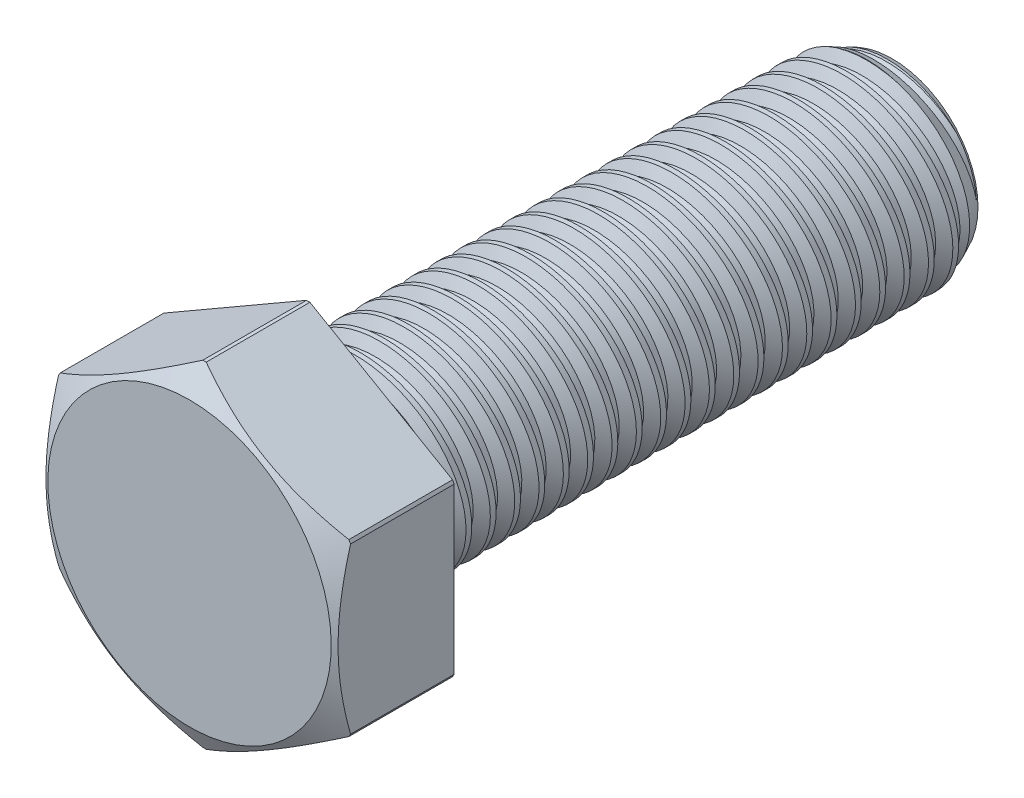
from build123d import *

# Parameters (mm, degrees)
SKETCH1_W            = 76.2
SKETCH1_H            = 12.7
LPATTERN1_COUNT      = 2
LPATTERN1_PITCH      = 3.175
LPATTERN1_COUNT_DIR2 = 24
LPATTERN1_PITCH_DIR2 = 3.175
EXTRUDE1_DEPTH       = 15.478125


with BuildPart() as part:
    # Sketch1 → Revolve1 (revolve)
    with BuildSketch(Plane(origin=(0, 0, 0), x_dir=(0, 0, -1), z_dir=(1, 0, 0)), mode=Mode.PRIVATE) as revolve1_sk:
        with Locations((0, 6.35)):
            Rectangle(SKETCH1_W, SKETCH1_H)
    revolve(revolve1_sk.sketch.rotate(Axis((0, 0, 38.1), (0, 0, 1)), 124.9636979), axis=Axis((0, 0, 38.1), (0, 0, 1)))

    # Sketch2 → Cut-Revolve1 (revolve, cut)
    with BuildSketch(Plane(origin=(0, 0, 0), x_dir=(0, 0, -1), z_dir=(1, 0, 0)), mode=Mode.PRIVATE) as cut_revolve1_sk:
        Polygon((-34.949517741, 13.093810282), (-37.706189718, 12.749226285), (-36.508507944, 11.167043455), (-35.720887379, 11.265496025), align=None)
    cut_revolve1 = revolve(cut_revolve1_sk.sketch.rotate(Axis((0, -0.423417007, 38.1), (0, 0.124034735, -0.992277877)), 180), axis=Axis((0, -0.423417007, 38.1), (0, 0.124034735, -0.992277877)), mode=Mode.SUBTRACT)

    # Sketch3 → Cut-Revolve2 (revolve, cut)
    with BuildSketch(Plane(origin=(0, 0, 0), x_dir=(0, 0, -1), z_dir=(1, 0, 0)), mode=Mode.PRIVATE) as cut_revolve2_sk:
        Polygon((34.81256408, 12.7), (38.1, 11.167043455), (38.1, 12.7), align=None)
    revolve(cut_revolve2_sk.sketch.rotate(Axis((0, 0, 0), (0, 0, -1)), 235.0363021), axis=Axis((0, 0, 0), (0, 0, -1)), mode=Mode.SUBTRACT)

    # LPattern1: Cut-Revolve1 2 × 24
    with Locations(*[Vector(0, 0, 1) * (i * LPATTERN1_PITCH) + Vector(0, 0, -1) * (j * LPATTERN1_PITCH_DIR2) for i in range(LPATTERN1_COUNT) for j in range(LPATTERN1_COUNT_DIR2) if (i, j) != (0, 0)]):
        add(cut_revolve1, mode=Mode.SUBTRACT)

    # Sketch5 → Extrude1 (add)
    with BuildSketch(Plane.XY.offset(38.1)):
        Polygon((0, 21.997045256), (-19.05, 10.998522628), (-19.05, -10.998522628), (0, -21.997045256), (19.05, -10.998522628), (19.05, 10.998522628), align=None)
    extrude(amount=EXTRUDE1_DEPTH)

    # Sketch6 → Cut-Revolve3 (revolve, cut)
    with BuildSketch(Plane(origin=(0, 0, 0), x_dir=(0, 0, -1), z_dir=(1, 0, 0)), mode=Mode.PRIVATE) as cut_revolve3_sk:
        Polygon((-53.578125, 18.4785), (-51.620015433, 21.870045256), (-38.1, 21.870045256), (-38.1, 22.378045256), (-53.578125, 22.378045256), align=None)
    revolve(cut_revolve3_sk.sketch.rotate(Axis((0, 0, 0), (0, 0, 1)), 124.9636979), axis=Axis((0, 0, 0), (0, 0, 1)), mode=Mode.SUBTRACT)


solid = part.part
